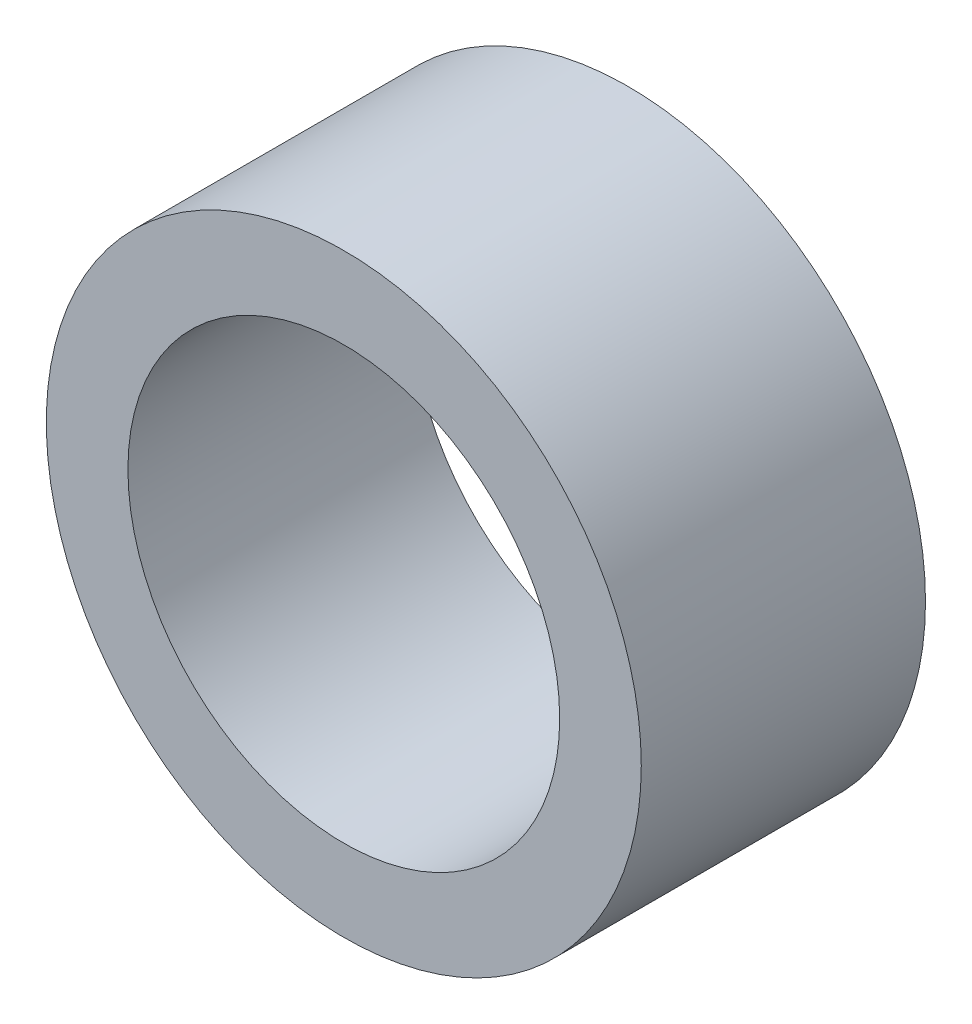
from build123d import *

# Parameters (mm, degrees)
SKETCH1_R      = 11.1125
SKETCH1_R_2    = 8.0645
EXTRUDE1_DEPTH = 5.3086


with BuildPart() as part:
    # Sketch1 → Extrude1 (new body, symmetric)
    with BuildSketch(Plane.XY):
        Circle(SKETCH1_R)
        Circle(SKETCH1_R_2, mode=Mode.SUBTRACT)
    extrude(amount=EXTRUDE1_DEPTH, both=True)


solid = part.part
